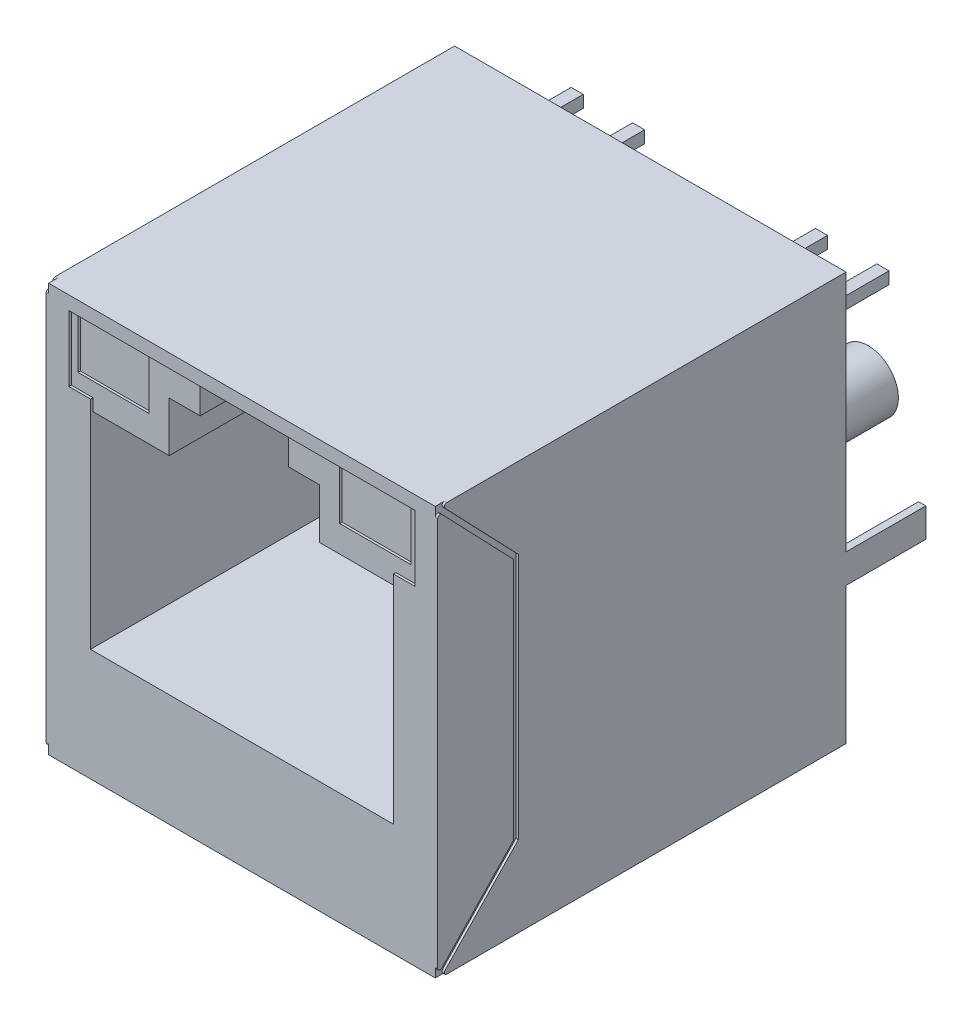
from build123d import *

# Parameters (mm, degrees)
SKETCH_1_W          = 16.2
SKETCH_1_H          = 16.9
EXTRUDE_1_DEPTH     = 16.9
CUT_EXTRUDE_1_DEPTH = 10
SKETCH_3_W          = 2.946300562
SKETCH_3_H          = 2.060350043
CUT_EXTRUDE_2_DEPTH = 0.2
SKETCH_4_W          = 14.323300114
SKETCH_4_H          = 2.725353119
CUT_EXTRUDE_3_DEPTH = 0.1
SKETCH_5_W          = 12.529891582
SKETCH_5_H          = 0.500524342
CUT_EXTRUDE_4_DEPTH = 0.1
CHAMFER_1_SIZE      = 0.5
CUT_EXTRUDE_5_DEPTH = 0.1
FILLET_1_R          = 0.1
SKETCH_7_R          = 1.25
SKETCH_7_W          = 0.5
SKETCH_7_H          = 0.4
SKETCH_7_H_2        = 0.5
SKETCH_7_W_2        = 0.3
SKETCH_7_H_3        = 1.2
EXTRUDE_2_DEPTH     = 3.3


with BuildPart() as part:
    # Эскиз1 → Бобышка-Вытянуть1 (new body)
    with BuildSketch(Plane.XY):
        Rectangle(SKETCH_1_W, SKETCH_1_H)
    extrude(amount=EXTRUDE_1_DEPTH)

    # Эскиз2 → Вырез-Вытянуть1 (cut)
    with BuildSketch(Plane.XY.offset(16.9)):
        Polygon((-6.264945791, -3.803921673), (-6.264945791, 4.664369649), (-3.10783524, 4.664369649), (-3.10783524, 6.730894781), (-1.828998264, 6.730894781), (-1.828998264, 7.89024711), (1.828998264, 7.89024711), (1.828998264, 6.730894781), (3.10783524, 6.730894781), (3.10783524, 4.664369649), (6.264945791, 4.664369649), (6.264945791, -3.803921673), align=None)
    extrude(amount=-CUT_EXTRUDE_1_DEPTH, mode=Mode.SUBTRACT)

    # Эскиз3 → Вырез-Вытянуть2 (cut)
    with BuildSketch(Plane.XY.offset(16.9)):
        with Locations((-5.415203287, 6.790232272)):
            Rectangle(SKETCH_3_W, SKETCH_3_H)
        with Locations((5.415203287, 6.790232272)):
            Rectangle(SKETCH_3_W, SKETCH_3_H)
    extrude(amount=-CUT_EXTRUDE_2_DEPTH, mode=Mode.SUBTRACT)

    # Эскиз4 → Вырез-Вытянуть3 (cut)
    with BuildSketch(Plane.XY.offset(16.9)):
        with Locations((0, 6.527570551)):
            Rectangle(SKETCH_4_W, SKETCH_4_H)
    extrude(amount=-CUT_EXTRUDE_3_DEPTH, mode=Mode.SUBTRACT)

    # Эскиз5 → Вырез-Вытянуть4 (cut)
    with BuildSketch(Plane.XY.offset(16.9)):
        with Locations((0, 4.91463182)):
            Rectangle(SKETCH_5_W, SKETCH_5_H)
    extrude(amount=-CUT_EXTRUDE_4_DEPTH, mode=Mode.SUBTRACT)

    # Фаска1
    chamfer_1_edges = [part.edges().sort_by_distance(p)[0] for p in [
        (0, -3.803921673, 6.9),
        (-6.264945791, 0.430223988, 6.9),
        (-4.686390516, 4.664369649, 6.9),
        (-3.10783524, 5.697632215, 6.9),
        (-2.468416752, 6.730894781, 6.9),
        (-1.828998264, 7.310570945, 6.9),
        (0, 7.89024711, 6.9),
        (1.828998264, 7.310570945, 6.9),
        (2.468416752, 6.730894781, 6.9),
        (3.10783524, 5.697632215, 6.9),
        (4.686390516, 4.664369649, 6.9),
        (6.264945791, 0.430223988, 6.9),
    ]]
    chamfer(chamfer_1_edges, length=CHAMFER_1_SIZE)

    # Эскиз6 → Вырез-Вытянуть5 (cut)
    with BuildSketch(Plane.ZY.offset(8.1)):
        Polygon((16.758546947, 8.45), (13.561955432, 5.115115471), (13.561955432, -5.115115471), (16.758546947, -8.45), (16.9, -8.45), (16.9, -8.308546947), (13.766132229, -5.039099757), (13.766132229, 5.039099757), (16.9, 8.308546947), (16.9, 8.45), align=None)
    cut_extrude_5 = extrude(amount=-CUT_EXTRUDE_5_DEPTH, mode=Mode.SUBTRACT)

    # Зеркальное отражение1: Вырез-Вытянуть5 across plane
    add(cut_extrude_5.mirror(Plane(origin=(0, 0, 0), x_dir=(0, 0, 1), z_dir=(1, 0, 0))), mode=Mode.SUBTRACT)

    # Скругление1
    fillet_1_edges = [part.edges().sort_by_distance(p)[0] for p in [
        (-8.05, 8.45, 16.758546947),
        (-8.05, 8.308546947, 16.9),
        (-8.05, -8.308546947, 16.9),
        (-8.05, -8.45, 16.758546947),
        (8.05, 8.45, 16.758546947),
        (8.05, -8.45, 16.758546947),
        (8.05, -8.308546947, 16.9),
        (8.05, 8.308546947, 16.9),
    ]]
    fillet(fillet_1_edges, radius=FILLET_1_R)

    # Эскиз7 → Бобышка-Вытянуть2 (add)
    with BuildSketch(Plane(origin=(0, 0, 0), x_dir=(-1, 0, 0), z_dir=(0, 0, -1))):
        with Locations((-5.715, 1.72)):
            Circle(SKETCH_7_R)
        with Locations((5.715, 1.72)):
            Circle(SKETCH_7_R)
        with Locations((-4.492372984, -4.63)):
            Rectangle(SKETCH_7_W, SKETCH_7_H)
        with Locations((-3.222372984, -7.17)):
            Rectangle(SKETCH_7_W, SKETCH_7_H)
        with Locations((-1.952372984, -4.63)):
            Rectangle(SKETCH_7_W, SKETCH_7_H)
        with Locations((-0.682372984, -7.17)):
            Rectangle(SKETCH_7_W, SKETCH_7_H)
        with Locations((0.587627016, -4.63)):
            Rectangle(SKETCH_7_W, SKETCH_7_H)
        with Locations((1.857627016, -7.17)):
            Rectangle(SKETCH_7_W, SKETCH_7_H)
        with Locations((3.127627016, -4.63)):
            Rectangle(SKETCH_7_W, SKETCH_7_H)
        with Locations((4.397627016, -7.17)):
            Rectangle(SKETCH_7_W, SKETCH_7_H)
        with Locations((-6.325, 5.83)):
            Rectangle(SKETCH_7_W, SKETCH_7_H_2)
        with Locations((-3.785, 5.83)):
            Rectangle(SKETCH_7_W, SKETCH_7_H_2)
        with Locations((3.785, 5.83)):
            Rectangle(SKETCH_7_W, SKETCH_7_H_2)
        with Locations((6.325, 5.83)):
            Rectangle(SKETCH_7_W, SKETCH_7_H_2)
        with Locations((-7.95, -2.18)):
            Rectangle(SKETCH_7_W_2, SKETCH_7_H_3)
        with Locations((7.95, -2.18)):
            Rectangle(SKETCH_7_W_2, SKETCH_7_H_3)
    extrude(amount=EXTRUDE_2_DEPTH)


solid = part.part
